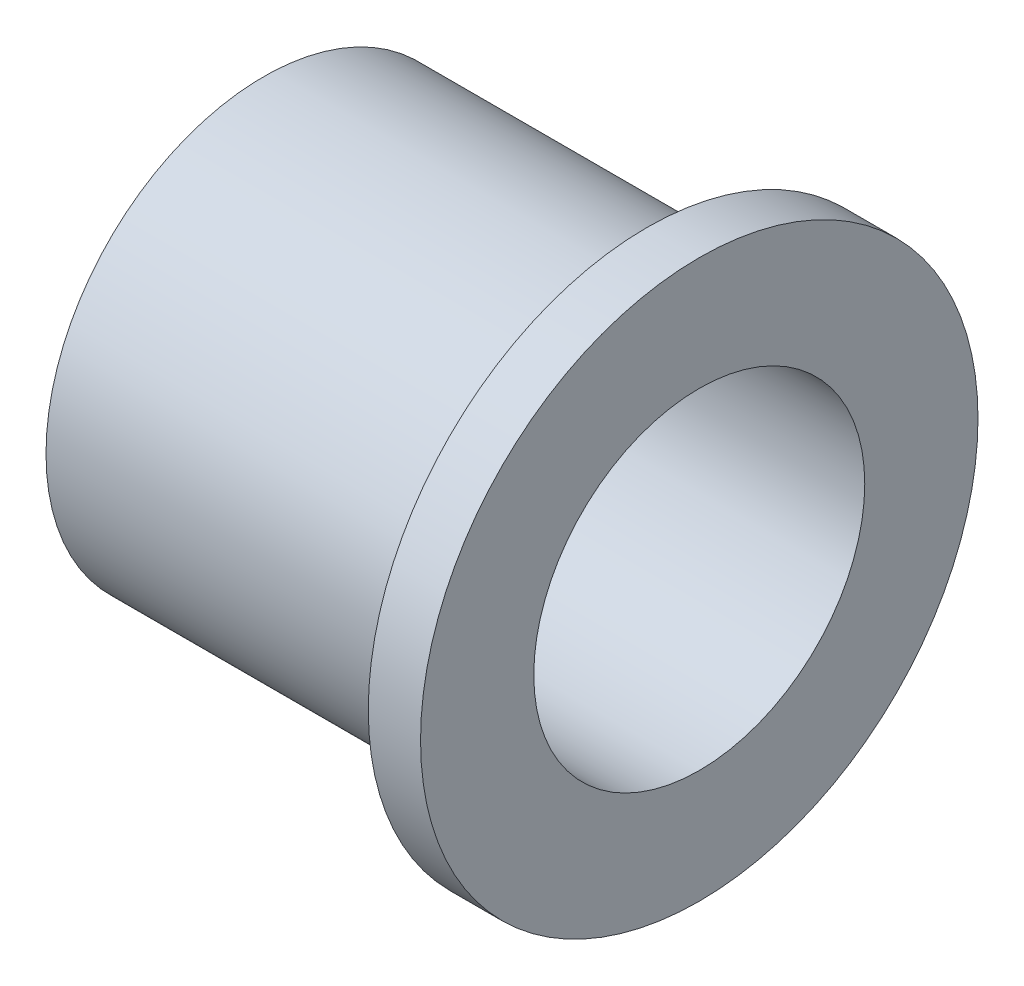
from build123d import *

# Parameters (mm, degrees)
ESBO_O1_R                = 12.5
RESSALTO_EXTRUS_O1_DEPTH = 22
ESBO_O2_R                = 16
RESSALTO_EXTRUS_O2_DEPTH = 3
ESBO_O3_R                = 9.5
CORTE_EXTRUS_O1_DEPTH    = 26


with BuildPart() as part:
    # Esboço1 → Ressalto-extrusão1 (new body)
    with BuildSketch(Plane(origin=(0, 0, 0), x_dir=(0, 0, -1), z_dir=(1, 0, 0))):
        Circle(ESBO_O1_R)
    extrude(amount=RESSALTO_EXTRUS_O1_DEPTH)

    # Esboço2 → Ressalto-extrusão2 (add)
    with BuildSketch(Plane(origin=(22, 0, 0), x_dir=(0, 0, -1), z_dir=(1, 0, 0))):
        Circle(ESBO_O2_R)
    extrude(amount=RESSALTO_EXTRUS_O2_DEPTH)

    # Esboço3 → Corte-extrusão1 (cut, through all)
    with BuildSketch(Plane(origin=(25, 0, 0), x_dir=(0, 0, -1), z_dir=(1, 0, 0))):
        Circle(ESBO_O3_R)
    extrude(amount=-CORTE_EXTRUS_O1_DEPTH, mode=Mode.SUBTRACT)


solid = part.part
